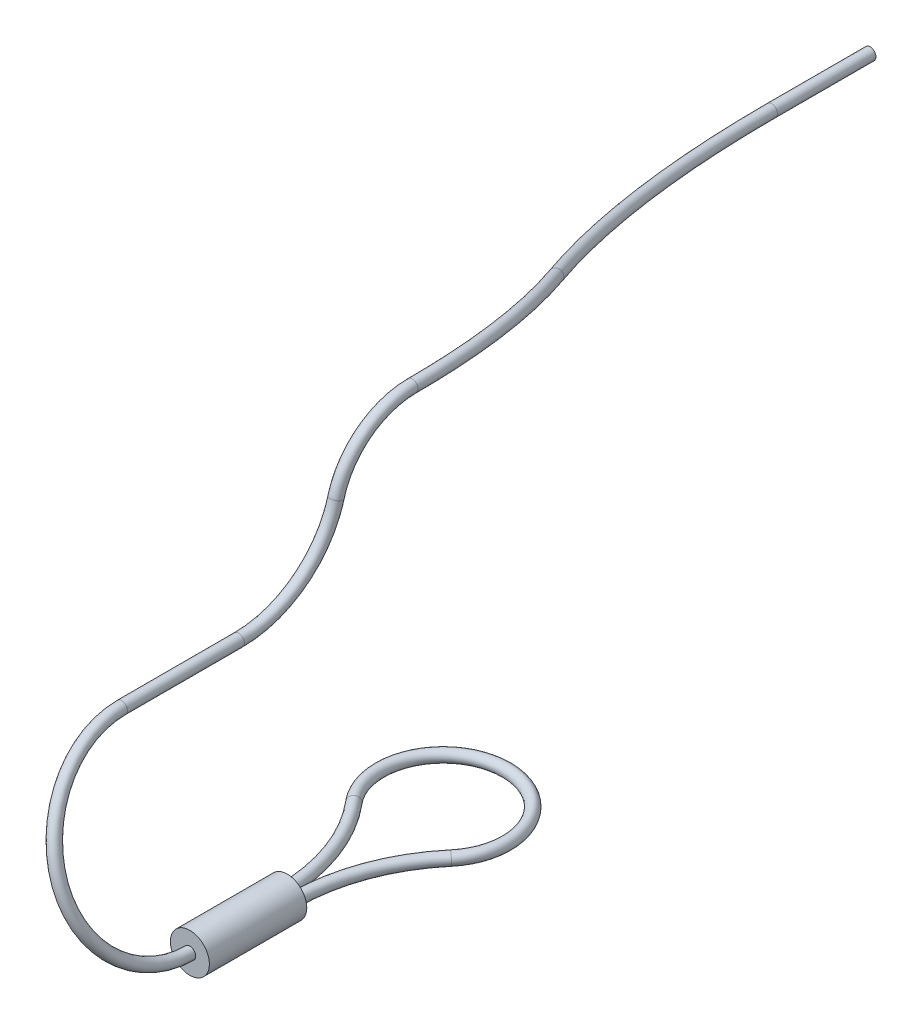
from build123d import *

# Parameters (mm, degrees)
SKETCH3_R      = 0.3
SKETCH4_R      = 1
EXTRUDE1_DEPTH = 5
SKETCH7_R      = 0.3
SKETCH8_R      = 0.3
SKETCH10_R     = 0.3


with BuildPart() as part:
    # Sweep1: sweep along a path in Sketch2
    with BuildLine(Plane(origin=(0, -13, 0), x_dir=(-1, 0, 0), z_dir=(0, 1, 0))) as sweep1_path:
        ThreePointArc((-10.325, 9), (-10.881554454, 5.85704491), (-12.483532031, 3.096322649))
        ThreePointArc((-12.483532031, 3.096322649), (-10, -2.25), (-7.516467969, 3.096322649))
        ThreePointArc((-7.516467969, 3.096322649), (-9.118445546, 5.85704491), (-9.675, 9))
    # Sketch3 → Sweep1 (sweep)
    with BuildSketch(Plane.XY.offset(9)):
        with Locations((10.325, -13)):
            Circle(SKETCH3_R)
    sweep(path=sweep1_path.line)

    # Sketch4 → Extrude1 (add)
    with BuildSketch(Plane.XY.offset(9)):
        with Locations((10, -13)):
            Circle(SKETCH4_R)
    extrude(amount=EXTRUDE1_DEPTH)

    # Sweep2: sweep along a path in Sketch6
    with BuildLine(Plane(origin=(4.393593056, 1.678158143, 0), x_dir=(0, 0, 1), z_dir=(-0.934175553, -0.356813727, 0))) as sweep2_path:
        ThreePointArc((14, -15.71241946), (18.904519834, -10.807899626), (14, -5.903379792))
    # Sketch7 → Sweep2 (sweep)
    with BuildSketch(Plane.XY.offset(14)):
        with Locations((10, -13)):
            Circle(SKETCH7_R)
    sweep(path=sweep2_path.line)

    # Sweep3: sweep along a path in Sketch5
    with BuildLine(Plane(origin=(6.5, 0, 0), x_dir=(0, 0, -1), z_dir=(1, 0, 0))) as sweep3_path:
        Line((-14, -3.83663494), (-8, -3.83663494))
        ThreePointArc((-8, -3.83663494), (-4.848818965, -2.766953117), (-3, 0))
        ThreePointArc((-3, 0), (-1.554343329, 2.163578105), (0.909676119, 3))
    # Sketch8 → Sweep3 (sweep)
    with BuildSketch(Plane(origin=(0, 0, 14), x_dir=(0.996598195, -0.08241382, 0), z_dir=(0, 0, -1))):
        with Locations((6.79408001, 3.287893624)):
            Circle(SKETCH8_R)
    sweep(path=sweep3_path.line)

    # Sweep4: sweep along a path in Sketch9
    with BuildLine(Plane(origin=(0, 0, 0), x_dir=(-0.907959385, -0.419058177, 0), z_dir=(-0.419058177, 0.907959385, 0))) as sweep4_path:
        Line((-1, -30), (-1, -24.95045136))
        ThreePointArc((-1, -24.95045136), (-1.93851681, -17.505305641), (-4.695346319, -10.525986215))
        ThreePointArc((-4.695346319, -10.525986215), (-6.533232658, -5.873106598), (-7.158910532, -0.909676119))
    # Sketch10 → Sweep4 (sweep)
    with BuildSketch(Plane(origin=(0, 0, -0.909676119), x_dir=(-1, 0, 0), z_dir=(0, 0, -1))):
        with Locations((-6.5, 3)):
            Circle(SKETCH10_R)
    sweep(path=sweep4_path.line)


solid = part.part
